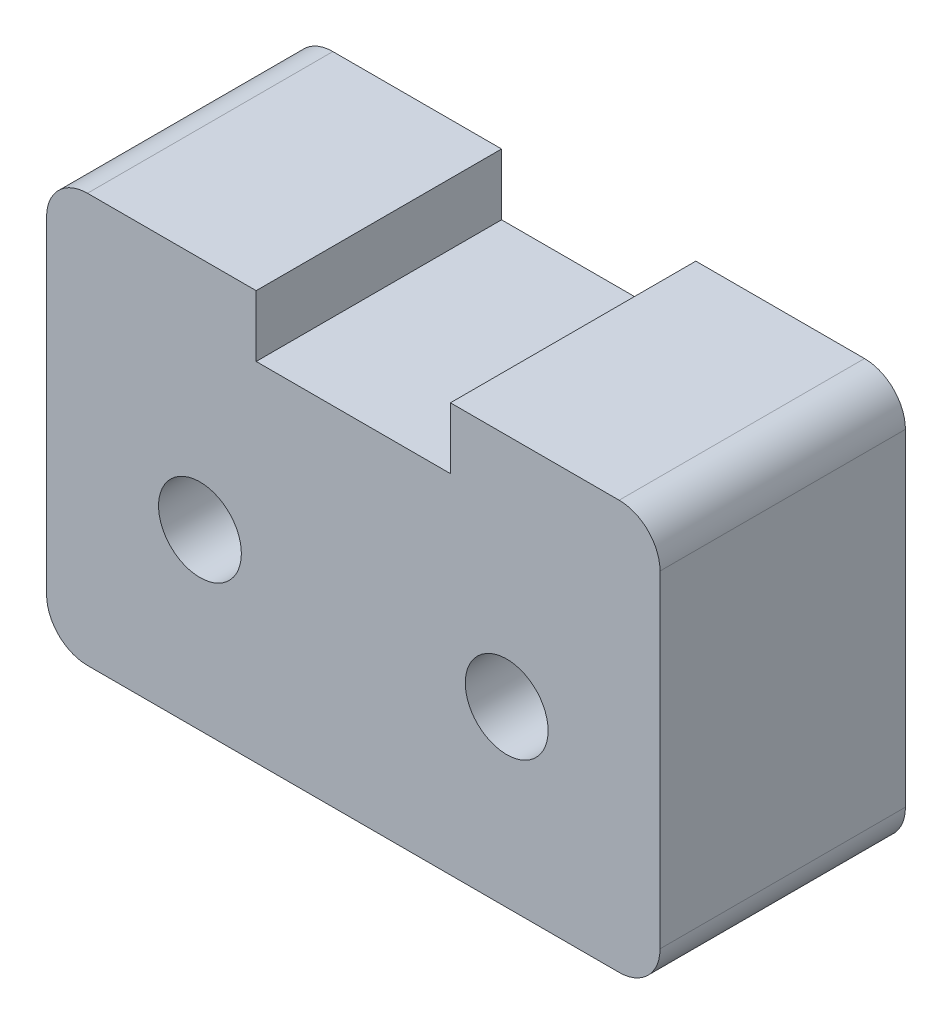
from build123d import *

# Parameters (mm, degrees)
EXTRUDE_1_DEPTH          = 12
FILLET_1_R               = 2
SKETCH_2_R               = 2.025
CUT_EXTRUDE_1_DEPTH      = 1
CUT_EXTRUDE_1_DEPTH_BACK = 13


with BuildPart() as part:
    # 草图1 → 凸台-拉伸1 (new body)
    with BuildSketch(Plane.XY):
        Polygon((4.75, 0), (-4.75, 0), (-4.75, 3), (-15, 3), (-15, -17), (15, -17), (15, 3), (4.75, 3), align=None)
    extrude(amount=EXTRUDE_1_DEPTH)

    # 圆角1
    fillet_1_edges = [part.edges().sort_by_distance(p)[0] for p in [
        (15, 3, 6),
        (15, -17, 6),
        (-15, -17, 6),
        (-15, 3, 6),
    ]]
    fillet(fillet_1_edges, radius=FILLET_1_R)

    # 草图2 → 切除-拉伸1 (cut, two sides)
    with BuildSketch(Plane.XY.offset(12)) as cut_extrude_1_sk:
        with Locations((-7.5, -8.5)):
            Circle(SKETCH_2_R)
        with Locations((7.5, -8.5)):
            Circle(SKETCH_2_R)
    extrude(amount=CUT_EXTRUDE_1_DEPTH, mode=Mode.SUBTRACT)
    extrude(cut_extrude_1_sk.sketch, amount=-CUT_EXTRUDE_1_DEPTH_BACK, mode=Mode.SUBTRACT)


solid = part.part
